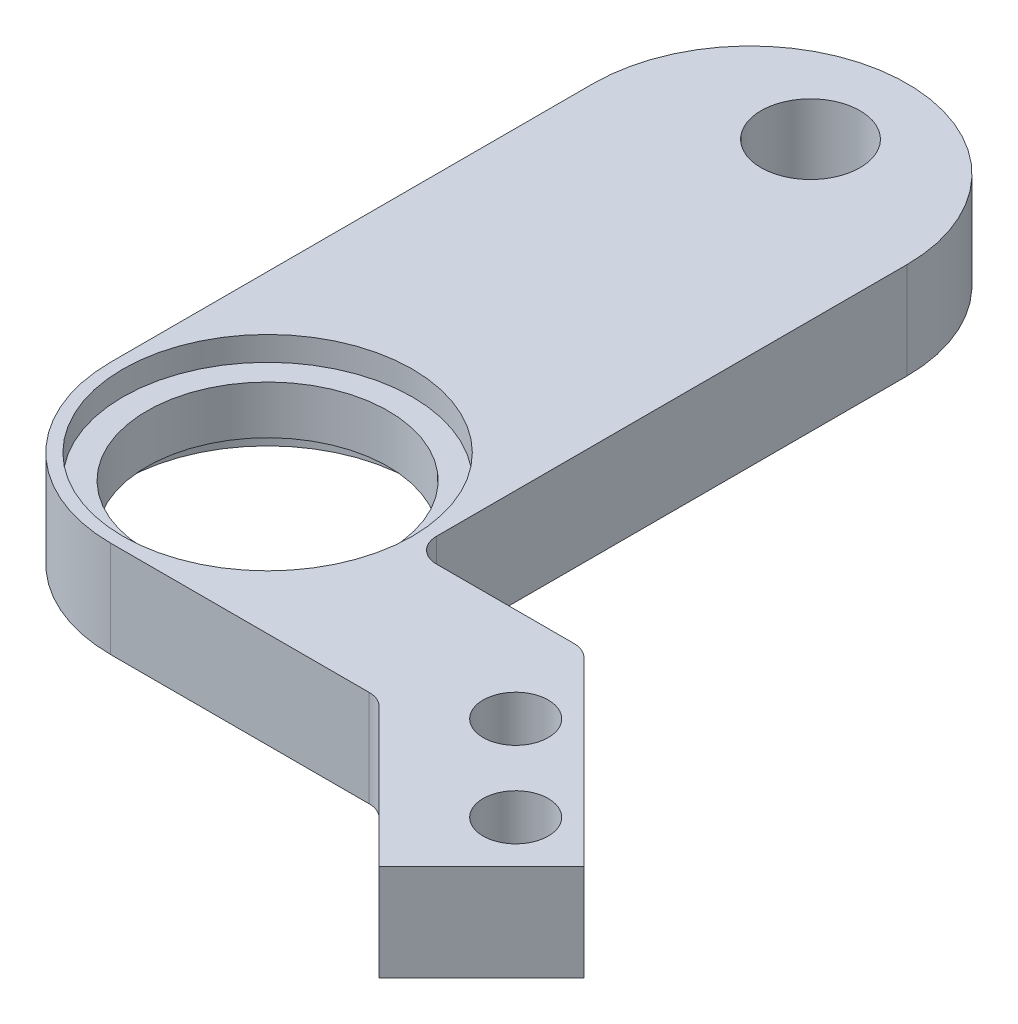
from build123d import *

# Parameters (mm, degrees)
BOSS_EXTRUDE1_DEPTH            = 4
DRAFT1_ANGLE                   = 45.000000004
DRAFT2_ANGLE                   = 45.000000005
F_4_1_4_1_DIAMETER_HOLE1_D     = 4.1
F_4_1_4_1_DIAMETER_HOLE1_DEPTH = 4
F_2_7_2_7_DIAMETER_HOLE1_D     = 2.7
F_2_7_2_7_DIAMETER_HOLE1_DEPTH = 4
FILLET1_R                      = 1
FILLET2_R                      = 6.5


with BuildPart() as part:
    # Sketch1 → Boss-Extrude1 (new body)
    with BuildSketch(Plane.XZ.offset(2)):
        with BuildLine():
            Line((11.124319466, 26.5), (-6.5, 26.5))
            Line((-6.5, 26.5), (-6.5, 0))
            ThreePointArc((-6.5, 0), (3e-09, -6.500000003), (6.500000005, 0))
            Line((6.500000005, 0), (6.500000005, 20.5))
            Line((6.500000005, 20.5), (13.60960084, 20.5))
            Line((13.60960084, 20.5), (13.60960084, 36.100603473))
            Line((13.60960084, 36.100603473), (11.124319466, 38.585884847))
            Line((11.124319466, 38.585884847), (11.124319466, 26.5))
        make_face()
    extrude(amount=-BOSS_EXTRUDE1_DEPTH)

    # Draft1
    draft1_faces = [part.faces().sort_by_distance(p)[0] for p in [
        (13.60960084, 0, 28.300301737),
    ]]
    draft(draft1_faces, Plane(origin=(6.500000005, 2, 20.5), x_dir=(-1, 0, 0), z_dir=(0, 0, -1)), DRAFT1_ANGLE)

    # Draft2
    draft2_faces = [part.faces().sort_by_distance(p)[0] for p in [
        (11.124319466, 0, 32.542942424),
    ]]
    draft(draft2_faces, Plane(origin=(11.124319466, 2, 26.5), x_dir=(1, 0, 0), z_dir=(0, 0, 1)), DRAFT2_ANGLE)

    # Sketch2 → Cut-Revolve1 (revolve, cut)
    with BuildSketch(Plane.XY.offset(20)):
        Polygon((6, 2), (0, 2), (0, -2), (6, -2), (6, -1), (5, -1), (5, 1), (6, 1), align=None)
    revolve(axis=Axis((0, 2, 20), (0, -1, 0)), mode=Mode.SUBTRACT)

    # Ø4.1 (4.1) Diameter Hole1
    with Locations(Plane(origin=(0, 2, 0), x_dir=(1, 0, 0), z_dir=(0, 1, 0))):
        with Locations((0, 2.5)):
            Hole(F_4_1_4_1_DIAMETER_HOLE1_D / 2, depth=F_4_1_4_1_DIAMETER_HOLE1_DEPTH)

    # Ø2.7 (2.7) Diameter Hole1
    with Locations(Plane(origin=(0, -2, 0), x_dir=(-1, 0, 0), z_dir=(0, -1, 0))):
        with Locations((-14.692388155, -24.41121444), (-18.227922061, -27.946748346)):
            Hole(F_2_7_2_7_DIAMETER_HOLE1_D / 2, depth=F_2_7_2_7_DIAMETER_HOLE1_DEPTH)

    # Fillet1
    fillet1_edges = [part.edges().sort_by_distance(p)[0] for p in [
        (13.60960084, 0, 20.5),
        (6.500000005, 0, 20.5),
        (11.124319466, 0, 26.5),
    ]]
    fillet(fillet1_edges, radius=FILLET1_R)

    # Fillet2
    fillet2_edges = [part.edges().sort_by_distance(p)[0] for p in [
        (-6.5, 0, 26.5),
    ]]
    fillet(fillet2_edges, radius=FILLET2_R)


solid = part.part
